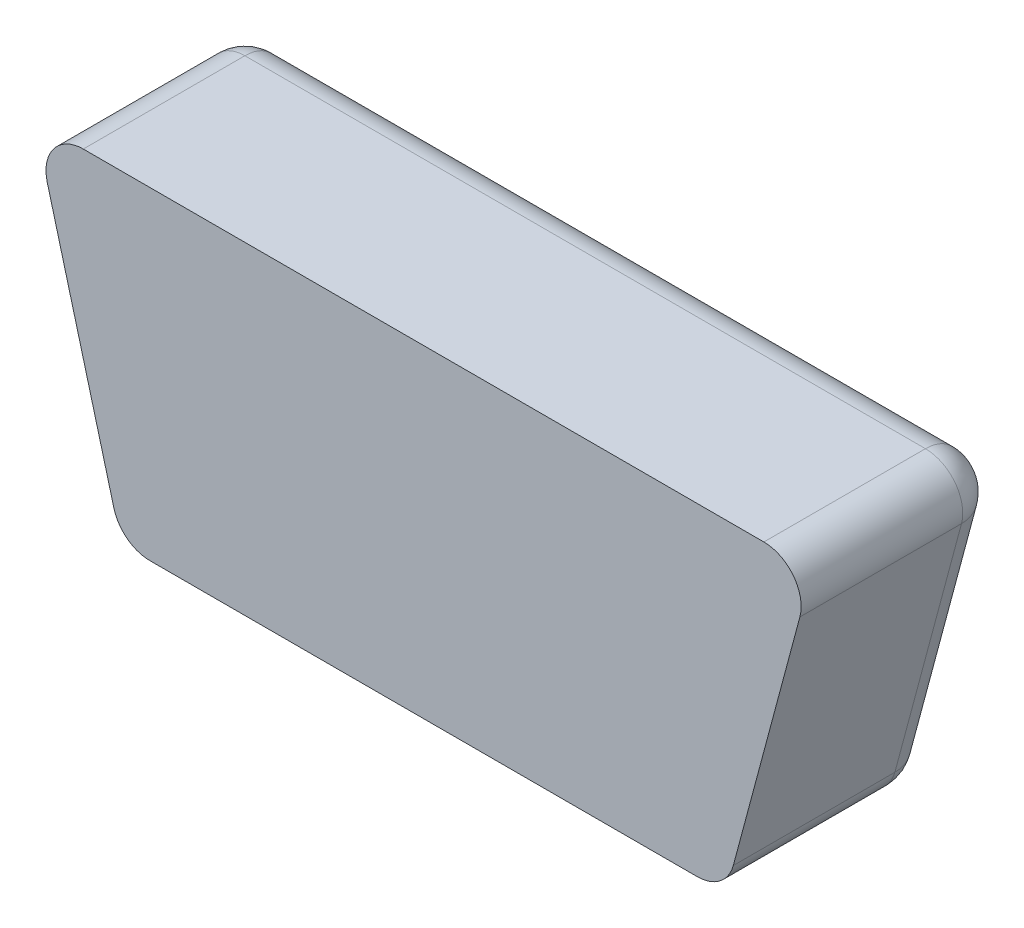
from build123d import *

# Parameters (mm, degrees)
EXTRUDE_1_DEPTH = 4
FILLET_1_R      = 0.75


with BuildPart() as part:
    # Эскиз1 → Бобышка-Вытянуть1 (new body)
    with BuildSketch(Plane.XY):
        Polygon((-6.08, -3.25), (6.08, -3.25), (7.821669751, 3.25), (-7.821669751, 3.25), align=None)
    extrude(amount=EXTRUDE_1_DEPTH)

    # Скругление1
    fillet_1_edges = [part.edges().sort_by_distance(p)[0] for p in [
        (0, 3.25, 0),
        (6.950834875, 0, 0),
        (0, -3.25, 0),
        (-6.950834875, 0, 0),
        (-7.821669751, 3.25, 2),
        (7.821669751, 3.25, 2),
        (6.08, -3.25, 2),
        (-6.08, -3.25, 2),
    ]]
    fillet(fillet_1_edges, radius=FILLET_1_R)


solid = part.part
